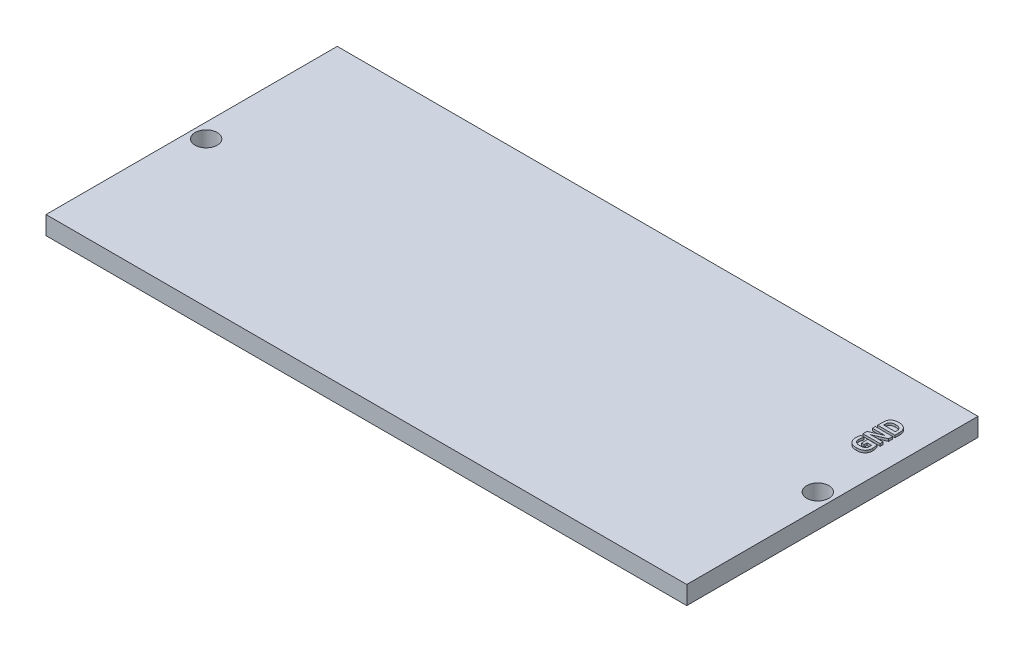
from build123d import *

# Parameters (mm, degrees)
SKETCH1_W             = 27.94
SKETCH1_H             = 12.7
BOSS_EXTRUDE1_DEPTH   = 0.8
BOSS_EXTRUDE3_DEPTH   = 0.1
BOSS_EXTRUDE3_2_DEPTH = 0.1
BOSS_EXTRUDE3_3_DEPTH = 0.1
SKETCH3_R             = 0.4826
CUT_EXTRUDE1_DEPTH    = 1.8


with BuildPart() as part:
    # Sketch1 → Boss-Extrude1 (new body)
    with BuildSketch(Plane(origin=(0, 0, 0), x_dir=(1, 0, 0), z_dir=(0, 1, 0))):
        Rectangle(SKETCH1_W, SKETCH1_H)
    extrude(amount=BOSS_EXTRUDE1_DEPTH)

    # Sketch3 → Cut-Extrude1 (cut, through all)
    with BuildSketch(Plane(origin=(0, 0.8, 0), x_dir=(1, 0, 0), z_dir=(0, 1, 0))):
        with Locations((-13.335, 0)):
            Circle(SKETCH3_R)
        with Locations((13.335, 0)):
            Circle(SKETCH3_R)
    extrude(amount=-CUT_EXTRUDE1_DEPTH, mode=Mode.SUBTRACT)


with BuildPart() as body_2:
    # Sketch2 → Boss-Extrude3 (new body)
    with BuildSketch(Plane(origin=(0, 0.8, 0), x_dir=(1, 0, 0), z_dir=(0, 1, 0))):
        with BuildLine():
            Line((12.654782609, 2.70326087), (12.535217391, 2.70326087))
            Line((12.535217391, 2.70326087), (12.535217391, 2.975))
            Line((12.535217391, 2.975), (12.933994565, 2.975))
            add(Edge.make_bspline(
                [(12.933994565, 2.975), (12.937837468, 2.966382306), (12.945532468, 2.949126304), (12.955152264, 2.922452152), (12.963165662, 2.895161446), (12.969582444, 2.867186739), (12.974756704, 2.838406753), (12.978239832, 2.808457977), (12.980539909, 2.777346131), (12.980758593, 2.756141049), (12.980869565, 2.745380435)],
                knots=[0, 0, 0, 0, 2.83e-05, 5.6667e-05, 8.4989e-05, 0.00011358, 0.000142731, 0.000172666, 0.000203994, 0.00023627, 0.00023627, 0.00023627, 0.00023627], degree=3))
            add(Edge.make_bspline(
                [(12.980869565, 2.745380435), (12.980575135, 2.732686426), (12.980000187, 2.70789819), (12.975544847, 2.671730082), (12.968102985, 2.637534066), (12.95758082, 2.605375869), (12.944174483, 2.57532413), (12.927751506, 2.547537374), (12.908296896, 2.522119124), (12.885871835, 2.499068556), (12.860656623, 2.478365329), (12.832343935, 2.460583289), (12.801398893, 2.444994305), (12.76754561, 2.432119366), (12.730828208, 2.422206945), (12.691431111, 2.414857144), (12.649210662, 2.41069843), (12.620144812, 2.410093731), (12.605190217, 2.409782609)],
                knots=[0, 0, 0, 0, 3.8074e-05, 7.4349e-05, 0.000109129, 0.000142911, 0.000175676, 0.000207657, 0.00023952, 0.000271469, 0.000303936, 0.000337152, 0.000371559, 0.000407737, 0.000445602, 0.000485509, 0.000527842, 0.000572705, 0.000572705, 0.000572705, 0.000572705], degree=3))
            add(Edge.make_bspline(
                [(12.605190217, 2.409782609), (12.590119329, 2.410063379), (12.560640948, 2.410612562), (12.517649028, 2.415264178), (12.477015917, 2.422834197), (12.438924245, 2.433501081), (12.40340077, 2.447069567), (12.37066987, 2.46356367), (12.340664417, 2.482851666), (12.313555861, 2.505027053), (12.289303043, 2.52985676), (12.268264698, 2.557527053), (12.250159996, 2.587749777), (12.235215685, 2.620684853), (12.223466349, 2.656149359), (12.215286825, 2.694073788), (12.210026575, 2.734307056), (12.209434125, 2.761950748), (12.209130435, 2.776120924)],
                knots=[0, 0, 0, 0, 4.5202e-05, 8.8415e-05, 0.000129553, 0.000169072, 0.000206921, 0.000243455, 0.000278834, 0.000313715, 0.000348305, 0.000382716, 0.000417755, 0.00045378, 0.000490999, 0.000529611, 0.000570015, 0.000612508, 0.000612508, 0.000612508, 0.000612508], degree=3))
            add(Edge.make_bspline(
                [(12.209130435, 2.776120924), (12.209532218, 2.793129262), (12.210329498, 2.826879873), (12.217434247, 2.876980037), (12.227746501, 2.9263664), (12.237062955, 2.958747212), (12.24173913, 2.975)],
                knots=[0, 0, 0, 0, 5.0999e-05, 0.0001012, 0.000151531, 0.00020225, 0.00020225, 0.00020225, 0.00020225], degree=3))
            Line((12.24173913, 2.975), (12.383043478, 2.975))
            add(Edge.make_bspline(
                [(12.383043478, 2.975), (12.379980993, 2.967778877), (12.373743753, 2.95307191), (12.365423125, 2.930202926), (12.358221837, 2.906110152), (12.351502266, 2.881255283), (12.346362637, 2.855715347), (12.342297504, 2.829954064), (12.340157423, 2.804010513), (12.339762417, 2.786654064), (12.339565217, 2.77798913)],
                knots=[0, 0, 0, 0, 2.3529e-05, 4.7921e-05, 7.2956e-05, 9.895e-05, 0.000125131, 0.000151072, 0.00017715, 0.000203149, 0.000203149, 0.000203149, 0.000203149], degree=3))
            add(Edge.make_bspline(
                [(12.339565217, 2.77798913), (12.339815286, 2.769432119), (12.34030236, 2.752765113), (12.343447714, 2.728538157), (12.349147142, 2.705902276), (12.356858098, 2.684749584), (12.367016557, 2.665384213), (12.378769875, 2.647446257), (12.392613504, 2.631346948), (12.408172988, 2.616681988), (12.425858915, 2.603987462), (12.445316436, 2.592660553), (12.466779836, 2.583250077), (12.490023007, 2.575418095), (12.514911387, 2.56933739), (12.541452876, 2.565226831), (12.569405263, 2.562357784), (12.588595139, 2.562092183), (12.598396739, 2.561956522)],
                knots=[0, 0, 0, 0, 2.5673e-05, 5.0005e-05, 7.3113e-05, 9.5575e-05, 0.000117376, 0.000138573, 0.000159776, 0.000180925, 0.000202564, 0.000224936, 0.000248354, 0.000272737, 0.000298441, 0.000325106, 0.000353261, 0.000382655, 0.000382655, 0.000382655, 0.000382655], degree=3))
            add(Edge.make_bspline(
                [(12.598396739, 2.561956522), (12.607855646, 2.562075031), (12.62634336, 2.56230666), (12.653314568, 2.564455477), (12.67893141, 2.567512732), (12.703015522, 2.572359742), (12.725710718, 2.578197941), (12.74645669, 2.586384894), (12.76574066, 2.595605891), (12.783117438, 2.606880689), (12.798645399, 2.619807192), (12.812297347, 2.634428016), (12.823846675, 2.65087516), (12.833678284, 2.669062622), (12.841293642, 2.689224243), (12.846708355, 2.71140086), (12.849932462, 2.735547695), (12.850263673, 2.752333528), (12.850434783, 2.761005435)],
                knots=[0, 0, 0, 0, 2.8371e-05, 5.5452e-05, 8.1131e-05, 0.000105712, 0.000129113, 0.000151318, 0.000172509, 0.000193143, 0.000213279, 0.000232988, 0.000252968, 0.000273408, 0.000294857, 0.00031743, 0.000341762, 0.000367767, 0.000367767, 0.000367767, 0.000367767], degree=3))
            add(Edge.make_bspline(
                [(12.850434783, 2.761005435), (12.850428671, 2.76502677), (12.850417297, 2.772510133), (12.84965684, 2.783099356), (12.848718815, 2.79264104), (12.847071406, 2.801443731), (12.845490001, 2.809753003), (12.843321763, 2.817657415), (12.840862664, 2.82554187), (12.839222527, 2.830920662), (12.838376359, 2.833695652)],
                knots=[0, 0, 0, 0, 1.206e-05, 2.2442e-05, 3.1838e-05, 4.0801e-05, 4.9295e-05, 5.7204e-05, 6.5371e-05, 7.4074e-05, 7.4074e-05, 7.4074e-05, 7.4074e-05], degree=3))
            Line((12.838376359, 2.833695652), (12.654782609, 2.833695652))
            Line((12.654782609, 2.833695652), (12.654782609, 2.70326087))
        make_face()
    extrude(amount=BOSS_EXTRUDE3_DEPTH)


with BuildPart() as body_3:
    # Sketch2 → Boss-Extrude3 2 (new body)
    with BuildSketch(Plane(origin=(0, 0.8, 0), x_dir=(1, 0, 0), z_dir=(0, 1, 0))):
        Polygon((12.97, 3.45326087), (12.52247962, 3.254891304), (12.426012228, 3.214130435), (12.736983696, 3.214130435), (12.97, 3.214130435), (12.97, 3.083695652), (12.22, 3.083695652), (12.22, 3.258967391), (12.670407609, 3.46107337), (12.758213315, 3.49673913), (12.427201087, 3.49673913), (12.22, 3.49673913), (12.22, 3.627173913), (12.97, 3.627173913), align=None)
    extrude(amount=BOSS_EXTRUDE3_2_DEPTH)


with BuildPart() as body_4:
    # Sketch2 → Boss-Extrude3 3 (new body)
    with BuildSketch(Plane(origin=(0, 0.8, 0), x_dir=(1, 0, 0), z_dir=(0, 1, 0))):
        with BuildLine():
            add(Edge.make_bspline(
                [(12.58548913, 4.290217391), (12.599710224, 4.289975652), (12.627533712, 4.289502692), (12.668263571, 4.285240593), (12.707047306, 4.278850222), (12.743677008, 4.269260397), (12.778055728, 4.25718027), (12.80998465, 4.242025479), (12.839124854, 4.223594949), (12.865678124, 4.20217252), (12.889688937, 4.177846254), (12.910460102, 4.149954132), (12.928585187, 4.119081437), (12.943495907, 4.084845598), (12.955426479, 4.047356907), (12.964029618, 4.00640729), (12.969102061, 3.961880726), (12.969693645, 3.931025897), (12.97, 3.915047554)],
                knots=[0, 0, 0, 0, 4.2651e-05, 8.3446e-05, 0.000122731, 0.000160464, 0.000196886, 0.000231905, 0.000266255, 0.000300073, 0.000334062, 0.000368505, 0.000404129, 0.000441239, 0.000480287, 0.000521958, 0.000566577, 0.000614501, 0.000614501, 0.000614501, 0.000614501], degree=3))
            Line((12.97, 3.915047554), (12.97, 3.725))
            Line((12.97, 3.725), (12.22, 3.725))
            Line((12.22, 3.725), (12.22, 3.946637228))
            add(Edge.make_bspline(
                [(12.22, 3.946637228), (12.220237689, 3.960518854), (12.220698643, 3.987439664), (12.224909749, 4.026487898), (12.231340527, 4.062888509), (12.240681124, 4.096654779), (12.25287599, 4.127737811), (12.26804846, 4.156160796), (12.286160399, 4.181864822), (12.307289513, 4.204852708), (12.331330057, 4.225177016), (12.358531463, 4.242568298), (12.388592407, 4.257411656), (12.421838105, 4.269386708), (12.458135011, 4.278956503), (12.497729156, 4.285327428), (12.540504801, 4.289532806), (12.570136214, 4.289983746), (12.58548913, 4.290217391)],
                knots=[0, 0, 0, 0, 4.1632e-05, 8.0738e-05, 0.000117682, 0.000152419, 0.00018566, 0.00021765, 0.000248844, 0.000279736, 0.000311072, 0.000343012, 0.000376356, 0.000411442, 0.000448846, 0.000488801, 0.000531625, 0.000577671, 0.000577671, 0.000577671, 0.000577671], degree=3))
        make_face()
        with BuildLine():
            add(Edge.make_bspline(
                [(12.594660326, 4.138043478), (12.584864589, 4.137886335), (12.565767958, 4.137579987), (12.537924462, 4.135979474), (12.511734986, 4.132904505), (12.487222162, 4.12869877), (12.464329042, 4.1233035), (12.443354505, 4.115691351), (12.42402882, 4.10678128), (12.40652124, 4.096024887), (12.390925185, 4.083410476), (12.37733451, 4.068760818), (12.365749837, 4.052184413), (12.356124233, 4.033583129), (12.348664549, 4.012791133), (12.343298257, 3.989776713), (12.340040163, 3.964393363), (12.33972816, 3.946704149), (12.339565217, 3.937466033)],
                knots=[0, 0, 0, 0, 2.939e-05, 5.7295e-05, 8.3628e-05, 0.00010845, 0.000131888, 0.000154074, 0.000175272, 0.000195633, 0.000215554, 0.000235262, 0.000255381, 0.000276043, 0.000297909, 0.000321473, 0.000346815, 0.000374517, 0.000374517, 0.000374517, 0.000374517], degree=3))
            Line((12.339565217, 3.937466033), (12.339565217, 3.866304348))
            Line((12.339565217, 3.866304348), (12.850434783, 3.866304348))
            Line((12.850434783, 3.866304348), (12.850434783, 3.927785326))
            add(Edge.make_bspline(
                [(12.850434783, 3.927785326), (12.850239672, 3.936116612), (12.849860166, 3.952321671), (12.846907915, 3.975848039), (12.842263839, 3.997905928), (12.835409562, 4.018383166), (12.826790511, 4.037346428), (12.816106699, 4.054729339), (12.803544216, 4.070569642), (12.788907206, 4.084791271), (12.772296576, 4.097556526), (12.753270496, 4.108275295), (12.732304426, 4.117765848), (12.708941442, 4.125085769), (12.683529028, 4.131080522), (12.655783654, 4.134976093), (12.625961423, 4.137610835), (12.60530974, 4.137896282), (12.594660326, 4.138043478)],
                knots=[0, 0, 0, 0, 2.4987e-05, 4.8601e-05, 7.1021e-05, 9.2503e-05, 0.00011325, 0.000133378, 0.000153563, 0.00017374, 0.00019446, 0.000216221, 0.000239105, 0.000263381, 0.000289541, 0.000317355, 0.000347355, 0.000379295, 0.000379295, 0.000379295, 0.000379295], degree=3))
        make_face(mode=Mode.SUBTRACT)
    extrude(amount=BOSS_EXTRUDE3_3_DEPTH)


solid = Compound([part.part, body_2.part, body_3.part, body_4.part])
